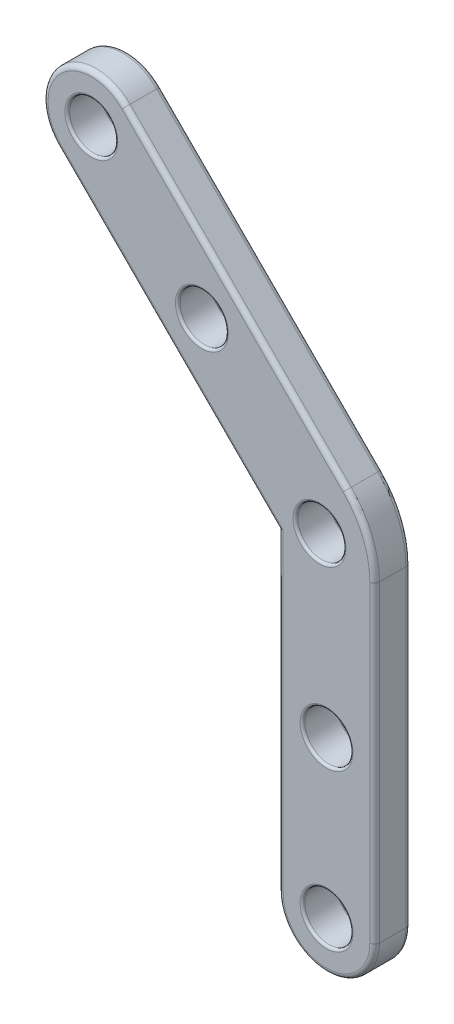
from build123d import *

# Parameters (mm, degrees)
BOSS_EXTRU_1_DEPTH      = 15
ESQUISSE2_R             = 10
ENL_V_MAT_EXTRU_2_DEPTH = 15
CONG_1_R                = 1
CONG_2_R                = 2


with BuildPart() as part:
    # Esquisse1 → Boss.-Extru.1 (new body)
    with BuildSketch(Plane.XY):
        with BuildLine():
            ThreePointArc((-40.283750746, 194.073988134), (-68.568021993, 194.073988134), (-68.568021993, 165.789716887))
            Line((-68.568021993, 165.789716887), (-40.283750746, 194.073988134))
        make_face()
        with BuildLine():
            Line((-40.283750746, 194.073988134), (-68.568021993, 165.789716887))
            ThreePointArc((-68.568021993, 165.789716887), (-46.772217722, 161.45426186), (-34.42588637, 179.931852511))
            ThreePointArc((-34.42588637, 179.931852511), (-35.948295719, 187.585521158), (-40.283750746, 194.073988134))
        make_face()
        with BuildLine():
            Line((-68.568021993, 165.789716887), (23.355859561, 73.865835333))
            Line((23.355859561, 73.865835333), (51.640130808, 102.15010658))
            Line((51.640130808, 102.15010658), (-40.283750746, 194.073988134))
            ThreePointArc((-40.283750746, 194.073988134), (-35.948295719, 187.585521158), (-34.42588637, 179.931852511))
            ThreePointArc((-34.42588637, 179.931852511), (-46.772217722, 161.45426186), (-68.568021993, 165.789716887))
        make_face()
        with BuildLine():
            Line((23.355859561, 73.865835333), (63.355859561, 73.865835333))
            ThreePointArc((63.355859561, 73.865835333), (60.311040861, 89.173172627), (51.640130808, 102.15010658))
            Line((51.640130808, 102.15010658), (23.355859561, 73.865835333))
        make_face()
        with BuildLine():
            Line((63.355859561, 73.865835333), (23.355859561, 73.865835333))
            Line((23.355859561, 73.865835333), (23.355859561, -56.134164667))
            ThreePointArc((23.355859561, -56.134164667), (43.355859561, -36.134164667), (63.355859561, -56.134164667))
            Line((63.355859561, -56.134164667), (63.355859561, 73.865835333))
        make_face()
        with BuildLine():
            ThreePointArc((63.355859561, -56.134164667), (43.355859561, -36.134164667), (23.355859561, -56.134164667))
            Line((23.355859561, -56.134164667), (63.355859561, -56.134164667))
        make_face()
        with BuildLine():
            Line((63.355859561, -56.134164667), (23.355859561, -56.134164667))
            ThreePointArc((23.355859561, -56.134164667), (43.355859561, -76.134164667), (63.355859561, -56.134164667))
        make_face()
    extrude(amount=BOSS_EXTRU_1_DEPTH)

    # Esquisse2 → Enlèv. mat.-Extru.2 (cut)
    with BuildSketch(Plane(origin=(0, 0, 0), x_dir=(-1, 0, 0), z_dir=(0, 0, -1))):
        with Locations((-40.426927373, 80.936903145)):
            Circle(ESQUISSE2_R)
        with Locations((54.42588637, 179.931852511)):
            Circle(ESQUISSE2_R)
        with Locations((8.463945593, 133.969911734)):
            Circle(ESQUISSE2_R)
        with Locations((-43.355859561, -56.134164667)):
            Circle(ESQUISSE2_R)
        with Locations((-43.355859561, 8.865835333)):
            Circle(ESQUISSE2_R)
    extrude(amount=-ENL_V_MAT_EXTRU_2_DEPTH, mode=Mode.SUBTRACT)

    # Congé1
    cong_1_edges = [part.edges().sort_by_distance(p)[0] for p in [
        (-44.42588637, 179.931852511, 15),
        (-44.42588637, 179.931852511, 0),
        (1.536054407, 133.969911734, 15),
        (1.536054407, 133.969911734, 0),
        (50.426927373, 80.936903145, 15),
        (50.426927373, 80.936903145, 0),
        (53.355859561, 8.865835333, 15),
        (53.355859561, 8.865835333, 0),
        (53.355859561, -56.134164667, 15),
        (53.355859561, -56.134164667, 0),
    ]]
    fillet(cong_1_edges, radius=CONG_1_R)

    # Congé2
    cong_2_edges = [part.edges().sort_by_distance(p)[0] for p in [
        (-22.606081216, 119.82777611, 0),
        (-68.568021993, 194.073988134, 0),
        (23.355859561, 8.865835333, 15),
        (43.355859561, -76.134164667, 15),
        (63.355859561, 8.865835333, 15),
        (60.311040861, 89.173172627, 15),
        (5.678190031, 148.112047357, 15),
        (-68.568021993, 194.073988134, 15),
        (5.678190031, 148.112047357, 0),
        (-22.606081216, 119.82777611, 15),
        (60.311040861, 89.173172627, 0),
        (63.355859561, 8.865835333, 0),
        (43.355859561, -76.134164667, 0),
        (23.355859561, 8.865835333, 0),
    ]]
    fillet(cong_2_edges, radius=CONG_2_R)


solid = part.part
